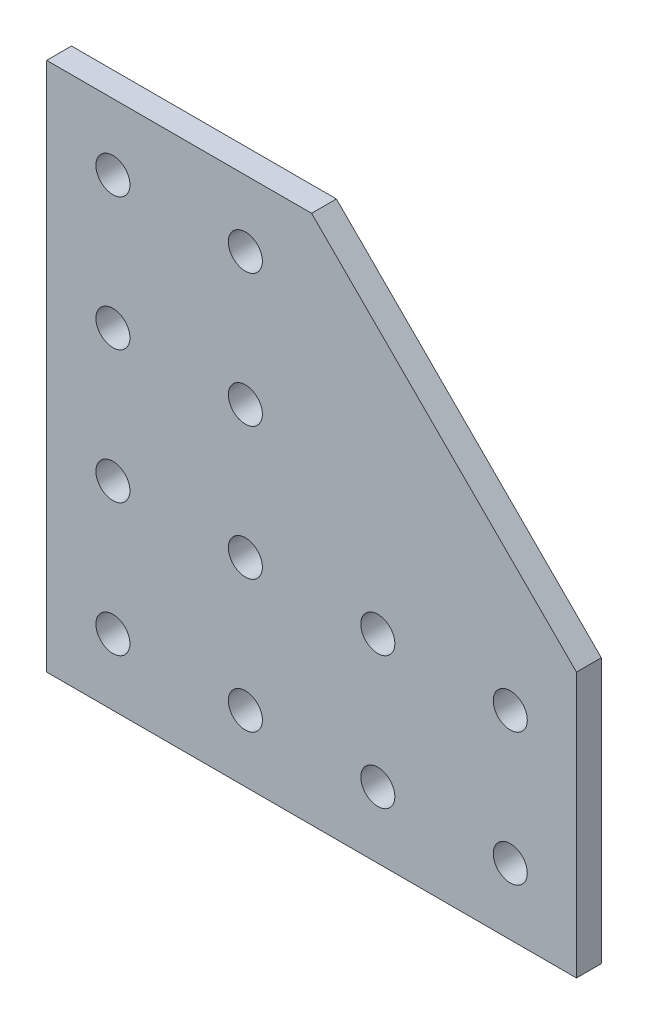
from build123d import *

# Parameters (mm, degrees)
SKETCH1_R           = 3.2639
BOSS_EXTRUDE1_DEPTH = 2.38125


with BuildPart() as part:
    # Sketch1 → Boss-Extrude1 (new body, symmetric)
    with BuildSketch(Plane.XY):
        Polygon((0, 0), (0, 101.6), (50.8, 101.6), (101.6, 50.8), (101.6, 0), align=None)
        with Locations((12.7, 12.7)):
            Circle(SKETCH1_R, mode=Mode.SUBTRACT)
        with Locations((38.1, 12.7)):
            Circle(SKETCH1_R, mode=Mode.SUBTRACT)
        with Locations((63.5, 12.7)):
            Circle(SKETCH1_R, mode=Mode.SUBTRACT)
        with Locations((12.7, 38.1)):
            Circle(SKETCH1_R, mode=Mode.SUBTRACT)
        with Locations((12.7, 63.5)):
            Circle(SKETCH1_R, mode=Mode.SUBTRACT)
        with Locations((88.9, 12.7)):
            Circle(SKETCH1_R, mode=Mode.SUBTRACT)
        with Locations((88.9, 38.1)):
            Circle(SKETCH1_R, mode=Mode.SUBTRACT)
        with Locations((63.5, 38.1)):
            Circle(SKETCH1_R, mode=Mode.SUBTRACT)
        with Locations((38.1, 38.1)):
            Circle(SKETCH1_R, mode=Mode.SUBTRACT)
        with Locations((12.7, 88.9)):
            Circle(SKETCH1_R, mode=Mode.SUBTRACT)
        with Locations((38.1, 88.9)):
            Circle(SKETCH1_R, mode=Mode.SUBTRACT)
        with Locations((38.1, 63.5)):
            Circle(SKETCH1_R, mode=Mode.SUBTRACT)
    extrude(amount=BOSS_EXTRUDE1_DEPTH, both=True)


solid = part.part
